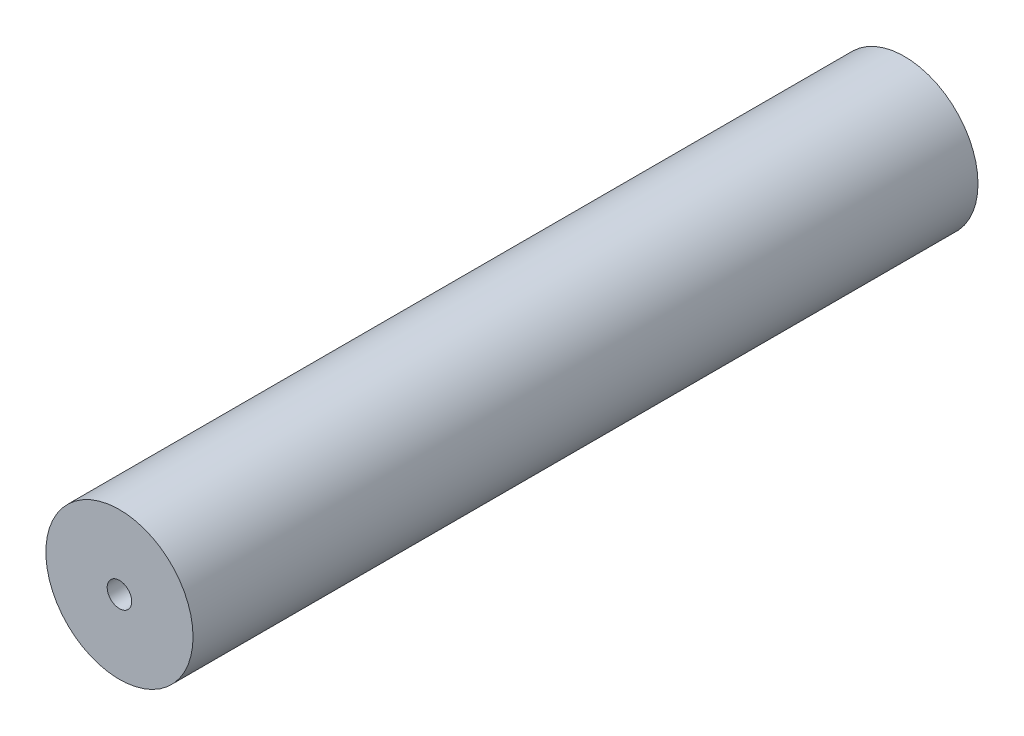
from build123d import *

# Parameters (mm, degrees)
SKETCH_1_R      = 7.5
EXTRUDE_1_DEPTH = 80
M3X0_5_1_D      = 2.5
M3X0_5_1_DEPTH  = 10
M3X0_5_1_TIP    = 0.751075774
M3X0_5_2_D      = 2.5
M3X0_5_2_DEPTH  = 10
M3X0_5_2_TIP    = 0.751075774


with BuildPart() as part:
    # ｽｹｯﾁ1 → ﾎﾞｽ - 押し出し1 (new body)
    with BuildSketch(Plane.XY):
        Circle(SKETCH_1_R)
    extrude(amount=EXTRUDE_1_DEPTH)

    # M3x0.5 ねじ穴1
    with Locations(Plane.XY.offset(80)):
        with Locations((0, 0)):
            Hole(M3X0_5_1_D / 2, depth=M3X0_5_1_DEPTH)
            with Locations((0, 0, -(M3X0_5_1_DEPTH + M3X0_5_1_TIP / 2))):  # 118° drill point
                Cone(0, M3X0_5_1_D / 2, M3X0_5_1_TIP, mode=Mode.SUBTRACT)

    # M3x0.5 ねじ穴2
    with Locations(Plane(origin=(0, 0, 0), x_dir=(-1, 0, 0), z_dir=(0, 0, -1))):
        with Locations((0, 0)):
            Hole(M3X0_5_2_D / 2, depth=M3X0_5_2_DEPTH)
            with Locations((0, 0, -(M3X0_5_2_DEPTH + M3X0_5_2_TIP / 2))):  # 118° drill point
                Cone(0, M3X0_5_2_D / 2, M3X0_5_2_TIP, mode=Mode.SUBTRACT)


solid = part.part
